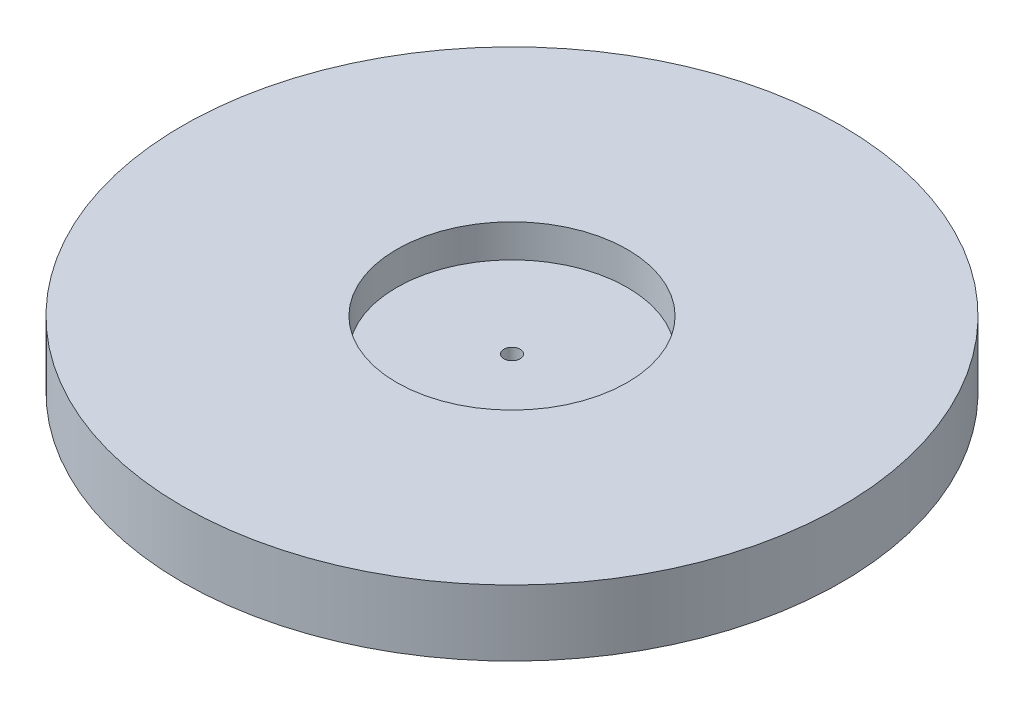
from build123d import *

# Parameters (mm, degrees)
SKETCH1_R           = 127
SKETCH1_R_2         = 3.175
BOSS_EXTRUDE1_DEPTH = 25.4
SKETCH3_R           = 44.45
CUT_EXTRUDE1_DEPTH  = 12.7


with BuildPart() as part:
    # Sketch1 → Boss-Extrude1 (new body)
    with BuildSketch(Plane(origin=(0, 0, 0), x_dir=(1, 0, 0), z_dir=(0, 1, 0))):
        Circle(SKETCH1_R)
        Circle(SKETCH1_R_2, mode=Mode.SUBTRACT)
    extrude(amount=BOSS_EXTRUDE1_DEPTH)

    # Sketch3 → Cut-Extrude1 (cut)
    with BuildSketch(Plane(origin=(0, 25.4, 0), x_dir=(1, 0, 0), z_dir=(0, 1, 0))):
        Circle(SKETCH3_R)
    extrude(amount=-CUT_EXTRUDE1_DEPTH, mode=Mode.SUBTRACT)


solid = part.part
